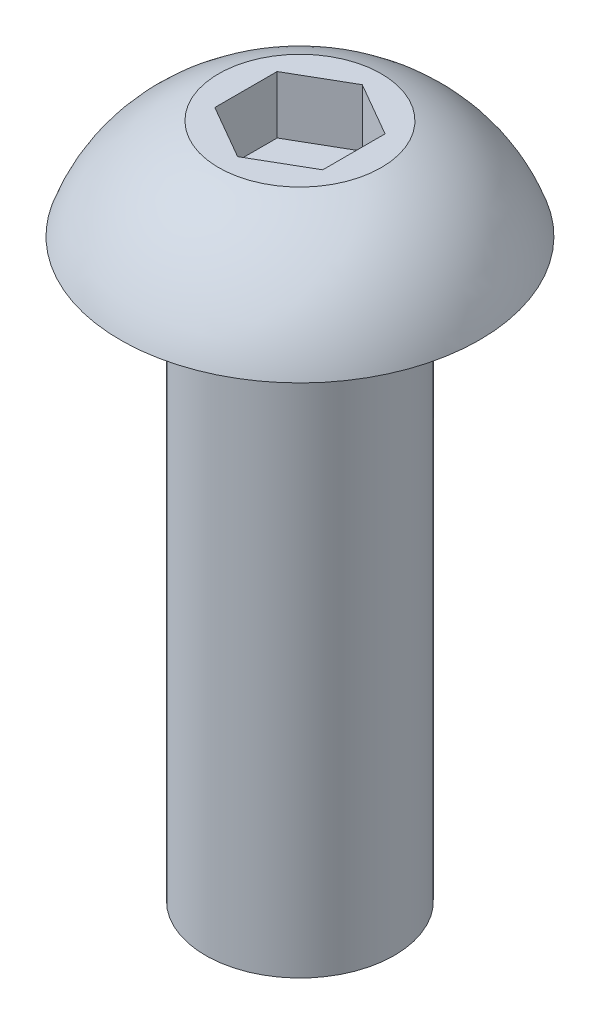
from build123d import *

# Parameters (mm, degrees)
CUT_EXTRUDE1_DEPTH = 1.27


with BuildPart() as part:
    # Sketch1 → Revolve1 (revolve)
    with BuildSketch(Plane.XY):
        with BuildLine():
            Line((-2.0828, 0), (-3.9624, 0))
            ThreePointArc((-3.9624, 0), (-3.131232795, 1.352726455), (-1.79477003, 2.2098))
            Line((-1.79477003, 2.2098), (0, 2.2098))
            Line((0, 2.2098), (0, -12.7))
            Line((0, -12.7), (-2.0828, -12.7))
            Line((-2.0828, -12.7), (-2.0828, 0))
        make_face()
    revolve(axis=Axis((0, -12.7, 0), (0, 1, 0)))

    # Sketch2 → Cut-Extrude1 (cut)
    with BuildSketch(Plane(origin=(0, 2.2098, 0), x_dir=(1, 0, 0), z_dir=(0, 1, 0))):
        Polygon((-1.190625, 0.687407664), (-1.190625, -0.687407664), (0, -1.374815329), (1.190625, -0.687407664), (1.190625, 0.687407664), (0, 1.374815329), align=None)
    extrude(amount=-CUT_EXTRUDE1_DEPTH, mode=Mode.SUBTRACT)


solid = part.part
